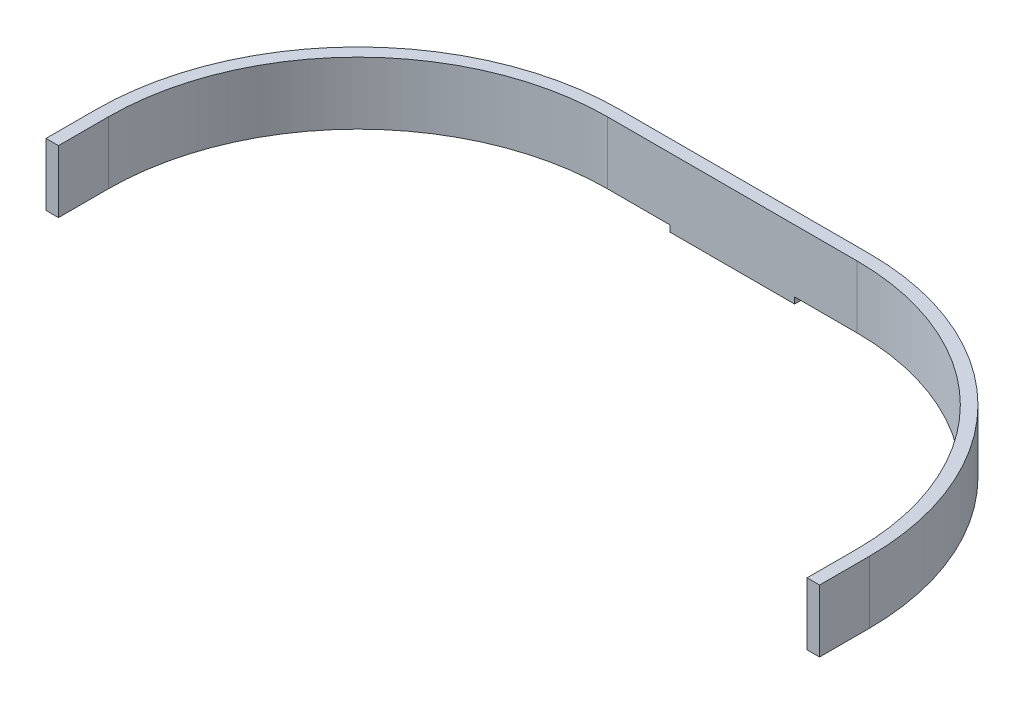
from build123d import *

# Parameters (mm, degrees)
EXTRUDE_1_DEPTH = 20
EXTRUDE_4_DEPTH = 20
SKETCH_10_R     = 6
EXTRUDE_5_DEPTH = 4


with BuildPart() as part:
    # 草图2 → 凸台-拉伸1 (new body, symmetric)
    with BuildSketch(Plane(origin=(0, 0, 0), x_dir=(0, 0, -1), z_dir=(1, 0, 0))):
        Polygon((-10, 1), (-8, 1), (-8, -1), (-10, -1), (-12, -1), (-12, 1), align=None)
    extrude(amount=EXTRUDE_1_DEPTH, both=True)

    # 草图9 → 凸台-拉伸4 (add)
    with BuildSketch(Plane(origin=(0, 1, 0), x_dir=(1, 0, 0), z_dir=(0, 1, 0))):
        with BuildLine():
            Line((-40, -8), (40, -8))
            ThreePointArc((40, -8), (99.39696962, -32.60303038), (124, -92))
            Line((124, -92), (124, -108))
            Line((124, -108), (120, -108))
            Line((120, -108), (120, -92))
            ThreePointArc((120, -92), (96.568542495, -35.431457505), (40, -12))
            Line((40, -12), (-40, -12))
            ThreePointArc((-40, -12), (-96.568542495, -35.431457505), (-120, -92))
            Line((-120, -92), (-120, -108))
            Line((-120, -108), (-124, -108))
            Line((-124, -108), (-124, -92))
            ThreePointArc((-124, -92), (-99.39696962, -32.60303038), (-40, -8))
        make_face()
    extrude(amount=EXTRUDE_4_DEPTH)

    # 草图10 → 凸台-拉伸5 (add)
    with BuildSketch(Plane(origin=(0, 0, 8), x_dir=(-1, 0, 0), z_dir=(0, 0, -1))):
        with Locations((0, 11)):
            Circle(SKETCH_10_R)
    extrude(amount=EXTRUDE_5_DEPTH)


solid = part.part
